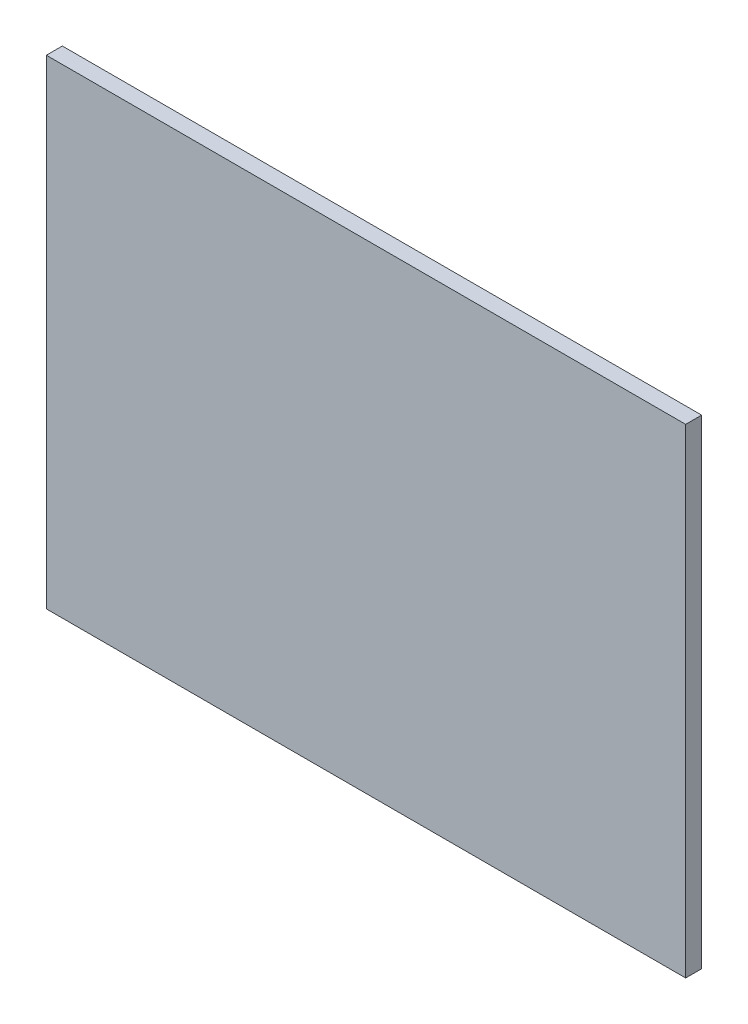
from build123d import *

# Parameters (mm, degrees)
SKETCH1_W           = 60
SKETCH1_H           = 45
BOSS_EXTRUDE1_DEPTH = 1.5


with BuildPart() as part:
    # Sketch1 → Boss-Extrude1 (new body)
    with BuildSketch(Plane.XY):
        Rectangle(SKETCH1_W, SKETCH1_H)
    extrude(amount=BOSS_EXTRUDE1_DEPTH)


solid = part.part
